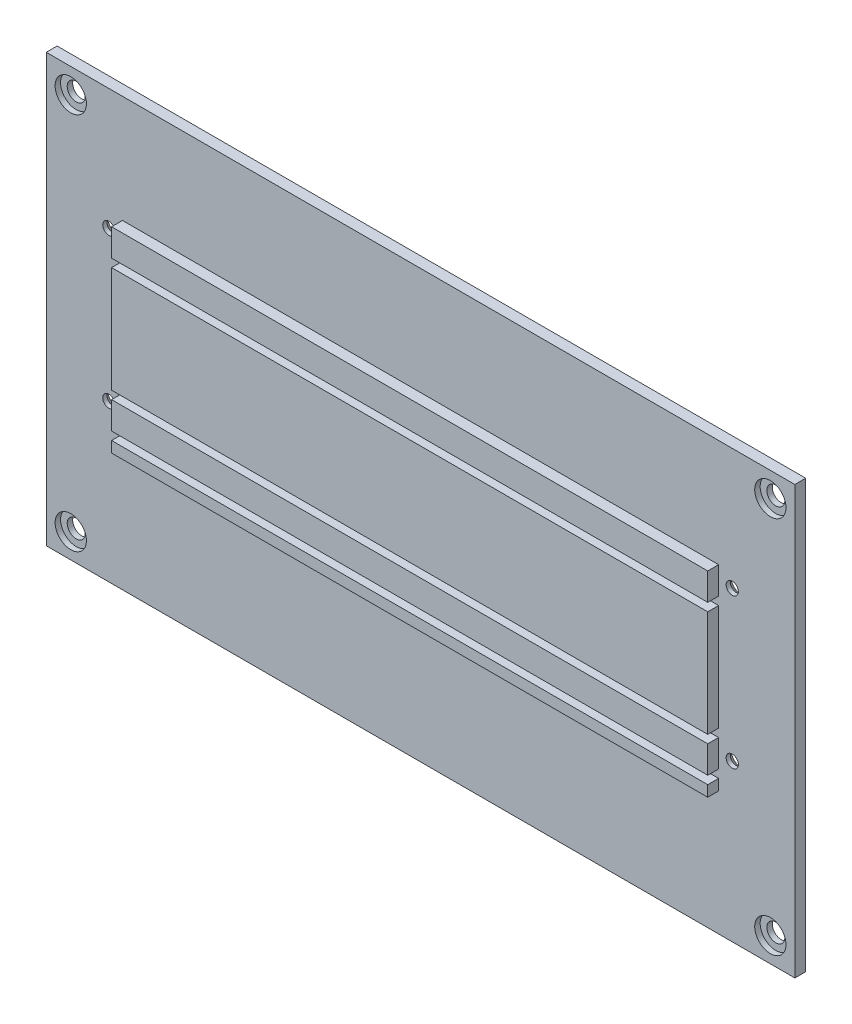
from build123d import *

# Parameters (mm, degrees)
ESQUISSE4_W                                      = 275
ESQUISSE4_H                                      = 157
BOSS_EXTRU_2_DEPTH                               = 4
FRAISAGE_POUR_VIS_T_TE_FRAIS_E_M42_AT_COUNT      = 2
FRAISAGE_POUR_VIS_T_TE_FRAIS_E_M42_AT_PITCH      = 235.512207752
FRAISAGE_POUR_VIS_T_TE_FRAIS_E_M42_2_COUNT       = 2
FRAISAGE_POUR_VIS_T_TE_FRAIS_E_M42_2_PITCH       = 229
FRAISAGE_POUR_VIS_T_TE_FRAIS_E_M42_3_COUNT       = 2
FRAISAGE_POUR_VIS_T_TE_FRAIS_E_M42_3_PITCH       = 55
CHAMBRAGE_POUR_VIS_T_TE_RONDE_6_PANS_D           = 6.6
CHAMBRAGE_POUR_VIS_T_TE_RONDE_6_PANS_CBORE_D     = 11.5
CHAMBRAGE_POUR_VIS_T_TE_RONDE_6_PANS_CBORE_DEPTH = 2
ESQUISSE9_W                                      = 219
ESQUISSE9_H                                      = 10
ESQUISSE9_H_2                                    = 39
ESQUISSE9_H_3                                    = 4
BOSS_EXTRU_3_DEPTH                               = 4


with BuildPart() as part:
    # Esquisse4 → Boss.-Extru.2 (new body)
    with BuildSketch(Plane.XY):
        Rectangle(ESQUISSE4_W, ESQUISSE4_H)
    extrude(amount=BOSS_EXTRU_2_DEPTH)

    # Esquisse6 → Fraisage pour vis à tête fraisée M42 (revolve, cut)
    with BuildSketch(Plane(origin=(-114.5, -21, 0), x_dir=(0, 1, 0), z_dir=(1, 0, 0))):
        Polygon((0, 0), (0, 4), (2.25, 4), (2.25, 2.45), (4.7, 0), align=None)
    fraisage_pour_vis_t_te_frais_e_m42 = revolve(axis=Axis((-114.5, -21, -6.35), (0, 0, 1)), mode=Mode.SUBTRACT)

    # Fraisage pour vis à tête fraisée M42 at: Fraisage pour vis à tête fraisée M42 ×2
    with Locations(*[Vector(0.972348747, 0.233533542, 0) * (i * FRAISAGE_POUR_VIS_T_TE_FRAIS_E_M42_AT_PITCH) for i in range(1, FRAISAGE_POUR_VIS_T_TE_FRAIS_E_M42_AT_COUNT)]):
        add(fraisage_pour_vis_t_te_frais_e_m42, mode=Mode.SUBTRACT)

    # Fraisage pour vis _ t_te frais_e M42 2: Fraisage pour vis à tête fraisée M42 ×2
    with Locations(*[(i * FRAISAGE_POUR_VIS_T_TE_FRAIS_E_M42_2_PITCH, 0, 0) for i in range(1, FRAISAGE_POUR_VIS_T_TE_FRAIS_E_M42_2_COUNT)]):
        add(fraisage_pour_vis_t_te_frais_e_m42, mode=Mode.SUBTRACT)

    # Fraisage pour vis _ t_te frais_e M42 3: Fraisage pour vis à tête fraisée M42 ×2
    with Locations(*[(0, i * FRAISAGE_POUR_VIS_T_TE_FRAIS_E_M42_3_PITCH, 0) for i in range(1, FRAISAGE_POUR_VIS_T_TE_FRAIS_E_M42_3_COUNT)]):
        add(fraisage_pour_vis_t_te_frais_e_m42, mode=Mode.SUBTRACT)

    # Chambrage pour Vis à tête ronde à 6 pans creux M61 (through all)
    with Locations(Plane.XY.offset(4)):
        with Locations((128.5, -69.5), (-128.5, -69.5), (-128.5, 69.5), (128.5, 69.5)):
            CounterBoreHole(CHAMBRAGE_POUR_VIS_T_TE_RONDE_6_PANS_D / 2, CHAMBRAGE_POUR_VIS_T_TE_RONDE_6_PANS_CBORE_D / 2, CHAMBRAGE_POUR_VIS_T_TE_RONDE_6_PANS_CBORE_DEPTH)

    # Esquisse9 → Boss.-Extru.3 (add)
    with BuildSketch(Plane.XY.offset(4)):
        with Locations((0, 34)):
            Rectangle(ESQUISSE9_W, ESQUISSE9_H)
        with Locations((0, 6.5)):
            Rectangle(ESQUISSE9_W, ESQUISSE9_H_2)
        with Locations((0, -21)):
            Rectangle(ESQUISSE9_W, ESQUISSE9_H)
        with Locations((0, -31)):
            Rectangle(ESQUISSE9_W, ESQUISSE9_H_3)
    extrude(amount=BOSS_EXTRU_3_DEPTH)


solid = part.part
